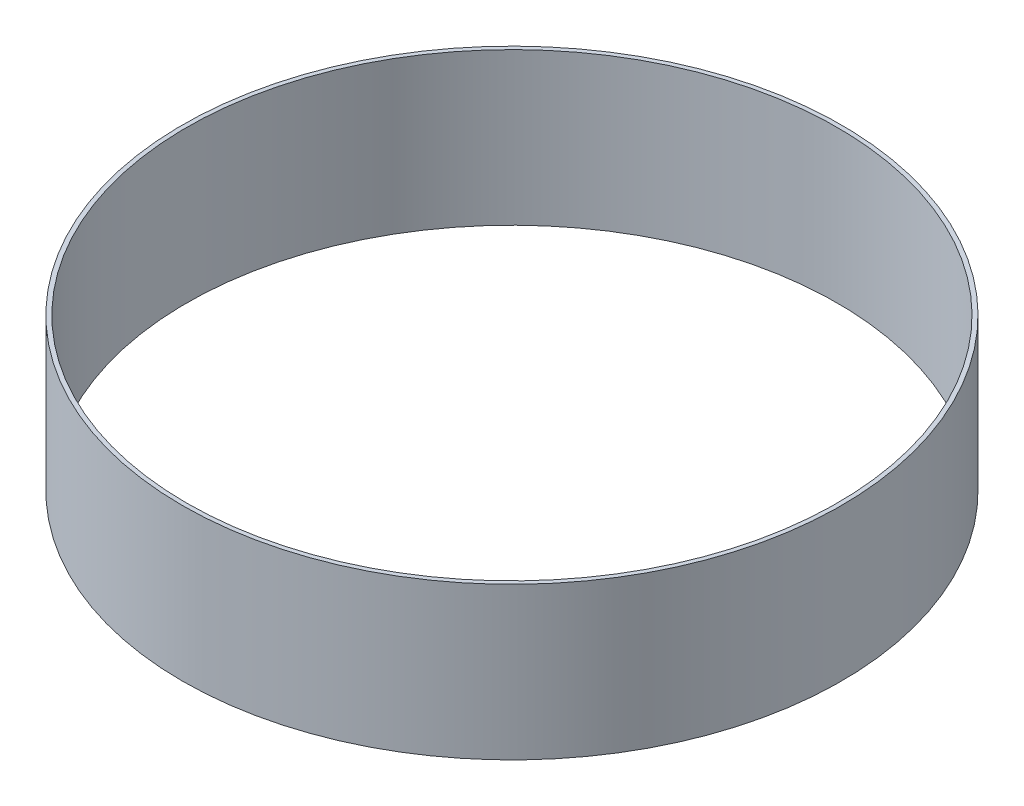
from build123d import *

# Parameters (mm, degrees)
SKETCH1_R           = 247.65
SKETCH1_R_2         = 244.475
BOSS_EXTRUDE1_DEPTH = 114.3


with BuildPart() as part:
    # Sketch1 → Boss-Extrude1 (new body)
    with BuildSketch(Plane(origin=(0, 0, 0), x_dir=(1, 0, 0), z_dir=(0, 1, 0))):
        Circle(SKETCH1_R)
        Circle(SKETCH1_R_2, mode=Mode.SUBTRACT)
    extrude(amount=BOSS_EXTRUDE1_DEPTH)


solid = part.part
